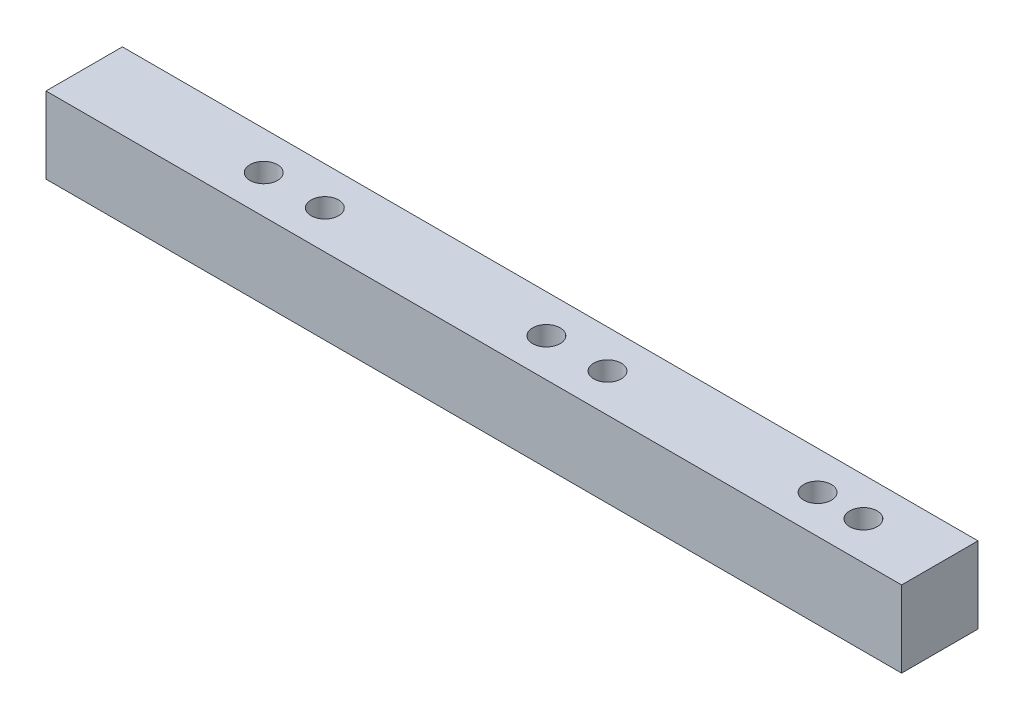
from build123d import *

# Parameters (mm, degrees)
SKETCH2_W           = 71.12
SKETCH2_H           = 6.35
BOSS_EXTRUDE1_DEPTH = 6.35
SKETCH3_R           = 1.143
CUT_EXTRUDE2_DEPTH  = 6.35


with BuildPart() as part:
    # Sketch2 → Boss-Extrude1 (new body)
    with BuildSketch(Plane.XY):
        with Locations((0, 3.175)):
            Rectangle(SKETCH2_W, SKETCH2_H)
    extrude(amount=BOSS_EXTRUDE1_DEPTH)

    # Sketch3 → Cut-Extrude2 (cut)
    with BuildSketch(Plane(origin=(0, 0, 0), x_dir=(1, 0, 0), z_dir=(0, 1, 0))):
        with Locations((-20.6375, -3.175)):
            Circle(SKETCH3_R)
        with Locations((-15.5575, -3.175)):
            Circle(SKETCH3_R)
        with Locations((2.8575, -3.175)):
            Circle(SKETCH3_R)
        with Locations((7.9375, -3.175)):
            Circle(SKETCH3_R)
        with Locations((25.4, -3.175)):
            Circle(SKETCH3_R)
        with Locations((29.21, -3.175)):
            Circle(SKETCH3_R)
    extrude(amount=CUT_EXTRUDE2_DEPTH, mode=Mode.SUBTRACT)


solid = part.part
